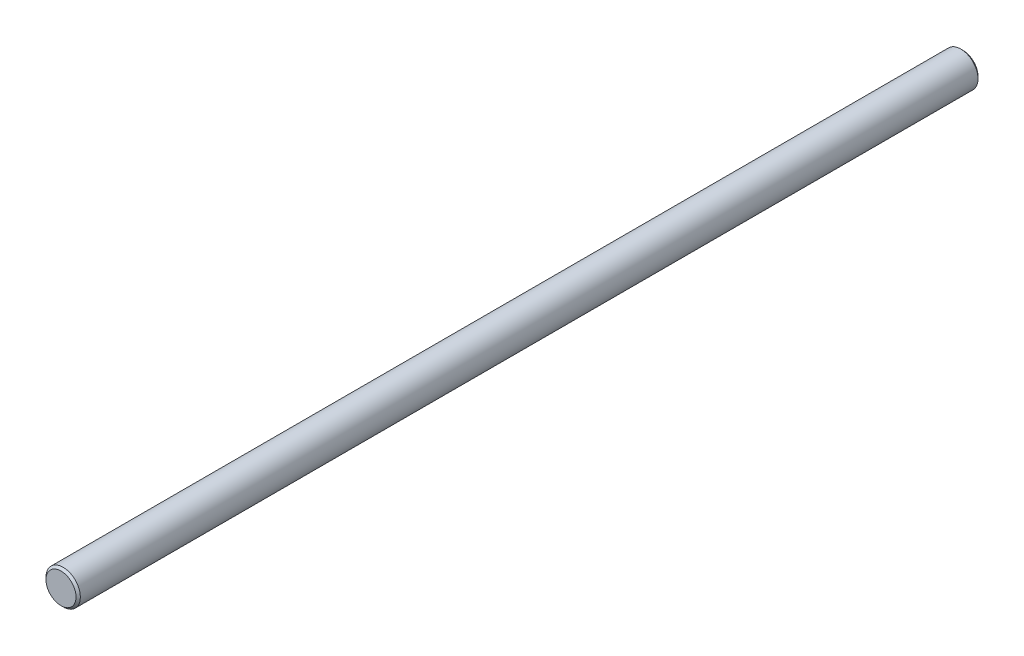
from build123d import *

# Parameters (mm, degrees)
SKETCH1_R           = 4
BOSS_EXTRUDE1_DEPTH = 210
CHAMFER1_SIZE       = 0.5


with BuildPart() as part:
    # Sketch1 → Boss-Extrude1 (new body)
    with BuildSketch(Plane.XY):
        Circle(SKETCH1_R)
    extrude(amount=-BOSS_EXTRUDE1_DEPTH)

    # Chamfer1
    chamfer1_edges = [part.edges().sort_by_distance(p)[0] for p in [
        (-4, 0, 0),
        (-4, 0, -210),
    ]]
    chamfer(chamfer1_edges, length=CHAMFER1_SIZE)


solid = part.part
